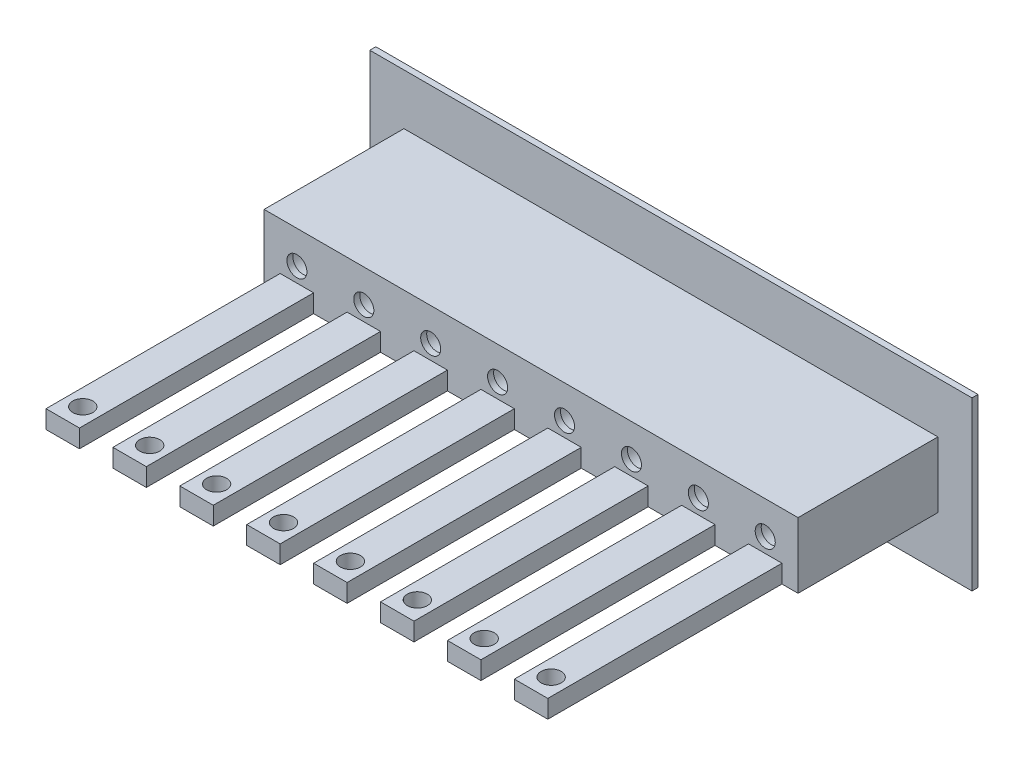
from build123d import *

# Parameters (mm, degrees)
CROQUIS1_W              = 90
CROQUIS1_H              = 25
SALIENTE_EXTRUIR1_DEPTH = 0.9
CROQUIS2_R              = 2.15
CORTAR_EXTRUIR1_DEPTH   = 0.9
CROQUIS3_W              = 79.8
CROQUIS3_H              = 9.8
CROQUIS3_R              = 2.15
SALIENTE_EXTRUIR2_DEPTH = 20
CROQUIS4_W              = 79.8
CROQUIS4_H              = 9.8
CROQUIS4_R              = 1.5
SALIENTE_EXTRUIR3_DEPTH = 0.9
CROQUIS5_W              = 5
CROQUIS5_H              = 35
CROQUIS5_R              = 1.5
SALIENTE_EXTRUIR4_DEPTH = 2.7


with BuildPart() as part:
    # Croquis1 → Saliente-Extruir1 (new body)
    with BuildSketch(Plane.XY):
        with Locations((-47.428766378, 9.852941176)):
            Rectangle(CROQUIS1_W, CROQUIS1_H)
    extrude(amount=SALIENTE_EXTRUIR1_DEPTH)

    # Croquis2 → Cortar-Extruir1 (cut)
    with BuildSketch(Plane.XY.offset(0.9)):
        with Locations((-82.428766378, 9.852941176)):
            Circle(CROQUIS2_R)
        with Locations((-72.428766378, 9.852941176)):
            Circle(CROQUIS2_R)
        with Locations((-62.428766378, 9.852941176)):
            Circle(CROQUIS2_R)
        with Locations((-52.428766378, 9.852941176)):
            Circle(CROQUIS2_R)
        with Locations((-42.428766378, 9.852941176)):
            Circle(CROQUIS2_R)
        with Locations((-32.428766378, 9.852941176)):
            Circle(CROQUIS2_R)
        with Locations((-22.428766378, 9.852941176)):
            Circle(CROQUIS2_R)
        with Locations((-12.428766378, 9.852941176)):
            Circle(CROQUIS2_R)
    extrude(amount=-CORTAR_EXTRUIR1_DEPTH, mode=Mode.SUBTRACT)

    # Croquis3 → Saliente-Extruir2 (add)
    with BuildSketch(Plane.XY.offset(0.9)):
        with Locations((-47.428766378, 9.852941176)):
            Rectangle(CROQUIS3_W, CROQUIS3_H)
        with Locations((-12.428766378, 9.852941176)):
            Circle(CROQUIS3_R, mode=Mode.SUBTRACT)
        with Locations((-22.428766378, 9.852941176)):
            Circle(CROQUIS3_R, mode=Mode.SUBTRACT)
        with Locations((-32.428766378, 9.852941176)):
            Circle(CROQUIS3_R, mode=Mode.SUBTRACT)
        with Locations((-42.428766378, 9.852941176)):
            Circle(CROQUIS3_R, mode=Mode.SUBTRACT)
        with Locations((-52.428766378, 9.852941176)):
            Circle(CROQUIS3_R, mode=Mode.SUBTRACT)
        with Locations((-62.428766378, 9.852941176)):
            Circle(CROQUIS3_R, mode=Mode.SUBTRACT)
        with Locations((-72.428766378, 9.852941176)):
            Circle(CROQUIS3_R, mode=Mode.SUBTRACT)
        with Locations((-82.428766378, 9.852941176)):
            Circle(CROQUIS3_R, mode=Mode.SUBTRACT)
    extrude(amount=SALIENTE_EXTRUIR2_DEPTH)

    # Croquis4 → Saliente-Extruir3 (add)
    with BuildSketch(Plane.XY.offset(20.9)):
        with Locations((-47.428766378, 9.852941176)):
            Rectangle(CROQUIS4_W, CROQUIS4_H)
        with Locations((-82.428766378, 9.852941176)):
            Circle(CROQUIS4_R, mode=Mode.SUBTRACT)
        with Locations((-72.428766378, 9.852941176)):
            Circle(CROQUIS4_R, mode=Mode.SUBTRACT)
        with Locations((-62.428766378, 9.852941176)):
            Circle(CROQUIS4_R, mode=Mode.SUBTRACT)
        with Locations((-52.428766378, 9.852941176)):
            Circle(CROQUIS4_R, mode=Mode.SUBTRACT)
        with Locations((-42.428766378, 9.852941176)):
            Circle(CROQUIS4_R, mode=Mode.SUBTRACT)
        with Locations((-32.428766378, 9.852941176)):
            Circle(CROQUIS4_R, mode=Mode.SUBTRACT)
        with Locations((-22.428766378, 9.852941176)):
            Circle(CROQUIS4_R, mode=Mode.SUBTRACT)
        with Locations((-12.428766378, 9.852941176)):
            Circle(CROQUIS4_R, mode=Mode.SUBTRACT)
    extrude(amount=SALIENTE_EXTRUIR3_DEPTH)

    # Croquis5 → Saliente-Extruir4 (add)
    with BuildSketch(Plane.XZ.offset(-4.952941176)):
        with Locations((-82.428766378, 39.3)):
            Rectangle(CROQUIS5_W, CROQUIS5_H)
        with Locations((-82.428766378, 53.8)):
            Circle(CROQUIS5_R, mode=Mode.SUBTRACT)
        with Locations((-72.428766378, 39.3)):
            Rectangle(CROQUIS5_W, CROQUIS5_H)
        with Locations((-72.428766378, 53.8)):
            Circle(CROQUIS5_R, mode=Mode.SUBTRACT)
        with Locations((-62.428766378, 39.3)):
            Rectangle(CROQUIS5_W, CROQUIS5_H)
        with Locations((-62.428766378, 53.8)):
            Circle(CROQUIS5_R, mode=Mode.SUBTRACT)
        with Locations((-52.428766378, 39.3)):
            Rectangle(CROQUIS5_W, CROQUIS5_H)
        with Locations((-52.428766378, 53.8)):
            Circle(CROQUIS5_R, mode=Mode.SUBTRACT)
        with Locations((-42.428766378, 39.3)):
            Rectangle(CROQUIS5_W, CROQUIS5_H)
        with Locations((-42.428766378, 53.8)):
            Circle(CROQUIS5_R, mode=Mode.SUBTRACT)
        with Locations((-32.428766378, 39.3)):
            Rectangle(CROQUIS5_W, CROQUIS5_H)
        with Locations((-32.428766378, 53.8)):
            Circle(CROQUIS5_R, mode=Mode.SUBTRACT)
        with Locations((-22.428766378, 39.3)):
            Rectangle(CROQUIS5_W, CROQUIS5_H)
        with Locations((-22.428766378, 53.8)):
            Circle(CROQUIS5_R, mode=Mode.SUBTRACT)
        with Locations((-12.428766378, 39.3)):
            Rectangle(CROQUIS5_W, CROQUIS5_H)
        with Locations((-12.428766378, 53.8)):
            Circle(CROQUIS5_R, mode=Mode.SUBTRACT)
    extrude(amount=-SALIENTE_EXTRUIR4_DEPTH)


solid = part.part
